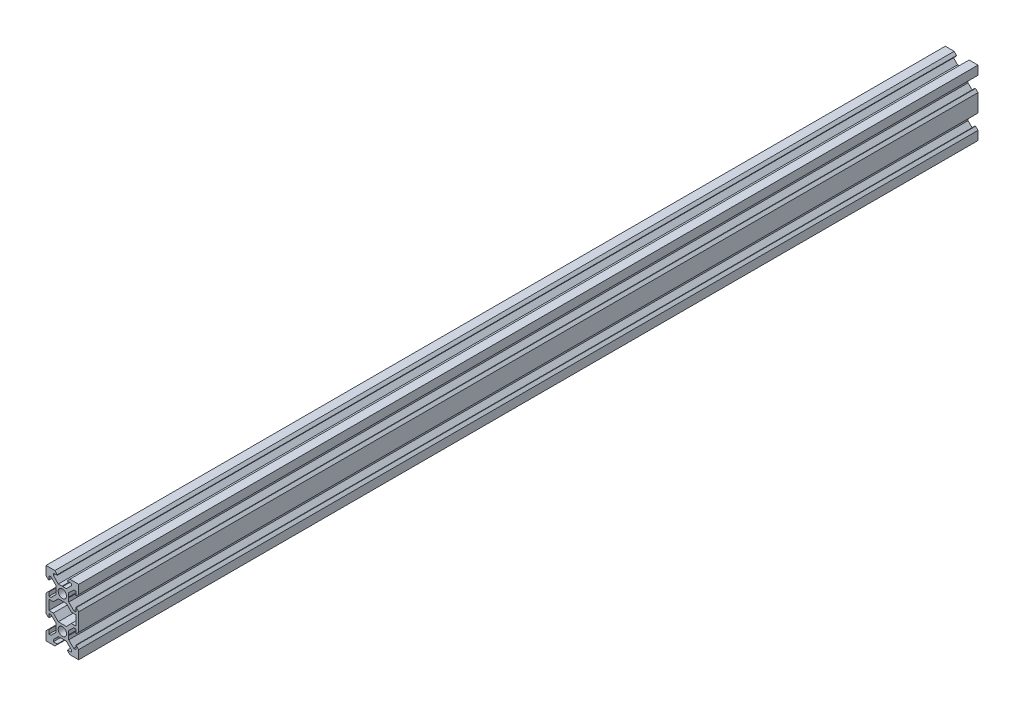
from build123d import *

# Parameters (mm, degrees)
SKETCH_1_R      = 2.55
EXTRUDE_1_DEPTH = 550


with BuildPart() as part:
    # Эскиз1 → Бобышка-Вытянуть1 (new body)
    with BuildSketch(Plane.XY.offset(792.9)):
        Polygon((-8.2, -3.125), (-8.506400721, -3.125), (-10, -4.58), (-10, -15.42), (-8.506400721, -16.875), (-8.2, -16.875), (-8.2, -14.5), (-7.00202244, -14.5), (-3.9, -17.521856474), (-3.9, -19.8), (-3.7, -20), (-3.9, -20.2), (-3.9, -22.478143526), (-7.00202244, -25.5), (-8.2, -25.5), (-8.2, -23.125), (-8.506400721, -23.125), (-10, -24.58), (-10, -30), (-4.58, -30), (-3.125, -28.506400721), (-3.125, -28.2), (-5.5, -28.2), (-5.5, -27.00202244), (-2.478143526, -23.9), (-0.2, -23.9), (0, -23.7), (0.2, -23.9), (2.478143526, -23.9), (5.5, -27.00202244), (5.5, -28.2), (3.125, -28.2), (3.125, -28.506400721), (4.58, -30), (10, -30), (10, -24.58), (8.506400721, -23.125), (8.2, -23.125), (8.2, -25.5), (7.00202244, -25.5), (3.9, -22.478143526), (3.9, -20.2), (3.7, -20), (3.9, -19.8), (3.9, -17.521856474), (7.00202244, -14.5), (8.2, -14.5), (8.2, -16.875), (8.506400721, -16.875), (10, -15.42), (10, -4.58), (8.506400721, -3.125), (8.2, -3.125), (8.2, -5.5), (7.00202244, -5.5), (3.9, -2.478143526), (3.9, -0.2), (3.7, 0), (3.9, 0.2), (3.9, 2.478143526), (7.00202244, 5.5), (8.2, 5.5), (8.2, 3.125), (8.506400721, 3.125), (10, 4.58), (10, 10), (4.58, 10), (3.125, 8.506400721), (3.125, 8.2), (5.5, 8.2), (5.5, 7.00202244), (2.478143526, 3.9), (0.2, 3.9), (0, 3.7), (-0.2, 3.9), (-2.478143526, 3.9), (-5.5, 7.00202244), (-5.5, 8.2), (-3.125, 8.2), (-3.125, 8.506400721), (-4.58, 10), (-10, 10), (-10, 4.58), (-8.506400721, 3.125), (-8.2, 3.125), (-8.2, 5.5), (-7.00202244, 5.5), (-3.9, 2.478143526), (-3.9, 0.2), (-3.7, 0), (-3.9, -0.2), (-3.9, -2.478143526), (-7.00202244, -5.5), (-8.2, -5.5), align=None)
        Circle(SKETCH_1_R, mode=Mode.SUBTRACT)
        with Locations((0, -20)):
            Circle(SKETCH_1_R, mode=Mode.SUBTRACT)
        Polygon((-2.478143526, -3.9), (2.478143526, -3.9), (5.5, -7.00202244), (8.2, -7.00202244), (8.2, -12.99797756), (5.5, -12.99797756), (2.478143526, -16.1), (-2.478143526, -16.1), (-5.5, -12.99797756), (-8.2, -12.99797756), (-8.2, -7.00202244), (-5.5, -7.00202244), align=None, mode=Mode.SUBTRACT)
    extrude(amount=-EXTRUDE_1_DEPTH)


solid = part.part
